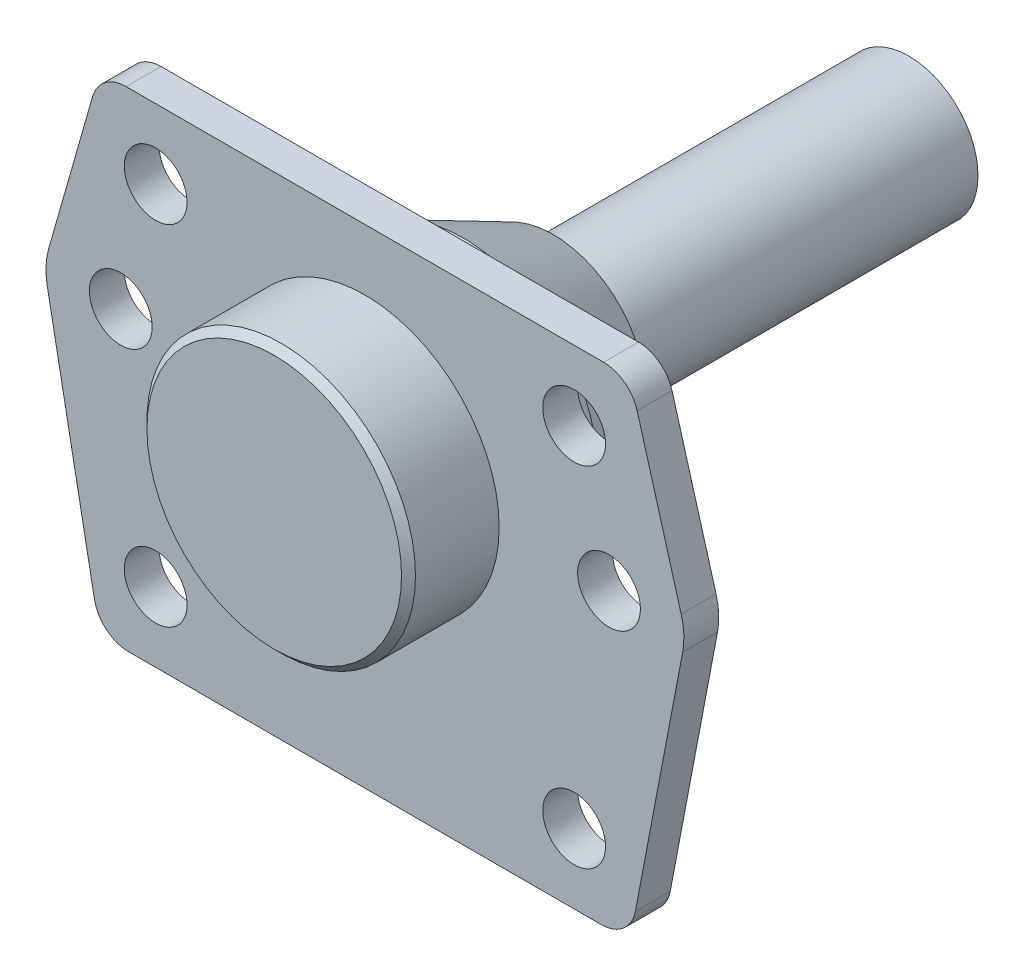
from build123d import *

# Parameters (mm, degrees)
ESQUISSE1_R             = 19.25
BOSS_EXTRU_1_DEPTH      = 13
BOSS_EXTRU_1_DEPTH_BACK = 27
ESQUISSE1_6_R           = 4.5
ESQUISSE1_6_R_2         = 19.25
BOSS_EXTRU_2_DEPTH      = 5
CHANFREIN1_SIZE         = 1
ESQUISSE6_R             = 9.9
BOSS_EXTRU_4_DEPTH      = 51
CHANFREIN2_SIZE         = 6
CHANFREIN2_SIZE2        = 12.867041523


with BuildPart() as part:
    # Esquisse1 → Boss.-Extru.1 (new body, two sides)
    with BuildSketch(Plane.XY) as boss_extru_1_sk:
        Circle(ESQUISSE1_R)
    extrude(amount=BOSS_EXTRU_1_DEPTH)
    extrude(boss_extru_1_sk.sketch, amount=-BOSS_EXTRU_1_DEPTH_BACK)

    # Esquisse1_6 → Boss.-Extru.2 (add)
    with BuildSketch(Plane.XY):
        with BuildLine():
            Line((34.228492936, 28), (0, 28))
            Line((0, 28), (-34.228492936, 28))
            ThreePointArc((-34.228492936, 28), (-37.239470502, 26.991743241), (-39.036112674, 24.373605639))
            Line((-39.036112674, 24.373605639), (-45.347302875, 2.284439938))
            ThreePointArc((-45.347302875, 2.284439938), (-45.721922521, -0.012532828), (-45.555449063, -2.33389242))
            Line((-45.555449063, -2.33389242), (-38.774178945, -37.935560539))
            ThreePointArc((-38.774178945, -37.935560539), (-37.050133937, -40.852129456), (-33.862486113, -42))
            Line((-33.862486113, -42), (33.862486113, -42))
            ThreePointArc((33.862486113, -42), (37.050133937, -40.852129456), (38.774178945, -37.935560539))
            Line((38.774178945, -37.935560539), (45.555449063, -2.33389242))
            ThreePointArc((45.555449063, -2.33389242), (45.721922521, -0.012532828), (45.347302875, 2.284439938))
            Line((45.347302875, 2.284439938), (39.036112674, 24.373605639))
            ThreePointArc((39.036112674, 24.373605639), (37.239470502, 26.991743241), (34.228492936, 28))
        make_face()
        with Locations((-30, -32)):
            Circle(ESQUISSE1_6_R, mode=Mode.SUBTRACT)
        with Locations((30, -32)):
            Circle(ESQUISSE1_6_R, mode=Mode.SUBTRACT)
        with Locations((-35, 0)):
            Circle(ESQUISSE1_6_R, mode=Mode.SUBTRACT)
        Circle(ESQUISSE1_6_R_2, mode=Mode.SUBTRACT)
        with Locations((-30, 18)):
            Circle(ESQUISSE1_6_R, mode=Mode.SUBTRACT)
        with Locations((35, 0)):
            Circle(ESQUISSE1_6_R, mode=Mode.SUBTRACT)
        with Locations((30, 18)):
            Circle(ESQUISSE1_6_R, mode=Mode.SUBTRACT)
    extrude(amount=-BOSS_EXTRU_2_DEPTH)

    # Chanfrein1
    chanfrein1_edges = [part.edges().sort_by_distance(p)[0] for p in [
        (-19.25, 0, 13),
    ]]
    chamfer(chanfrein1_edges, length=CHANFREIN1_SIZE)

    # Esquisse6 → Boss.-Extru.4 (add)
    with BuildSketch(Plane(origin=(0, 0, -27), x_dir=(-1, 0, 0), z_dir=(0, 0, -1))):
        with Locations(Location((0, 0, 0), (0, 0, 180))):  # turned: the seam where the file's is
            Circle(ESQUISSE6_R)
    extrude(amount=BOSS_EXTRU_4_DEPTH)

    # Chanfrein2
    chanfrein2_edges = [part.edges().sort_by_distance(p)[0] for p in [
        (-19.25, 0, -27),
    ]]
    chanfrein2_side = [part.faces().sort_by_distance(p)[0] for p in [
        (-18.705527778, 0, -27),
    ]]
    chamfer(chanfrein2_edges, length=CHANFREIN2_SIZE, length2=CHANFREIN2_SIZE2, reference=chanfrein2_side[0])


solid = part.part
